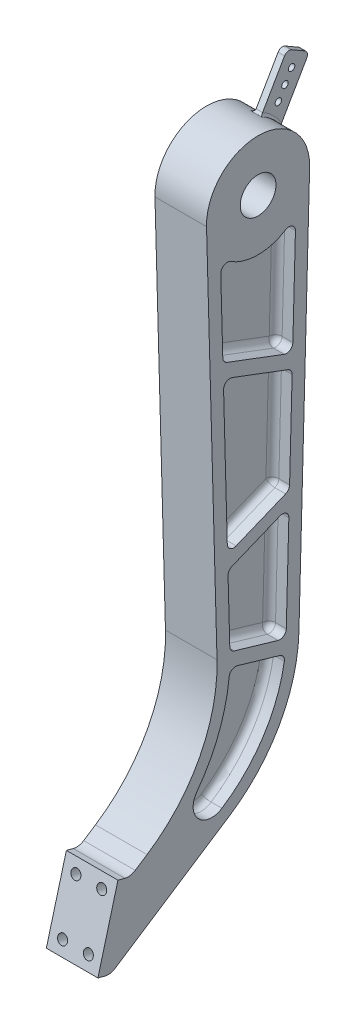
from build123d import *

# Parameters (mm, degrees)
SKETCH1_R            = 8.8003507
BOSS_EXTRUDE1_DEPTH  = 12.7
CUT_EXTRUDE1_DEPTH   = 8.466666667
FILLET1_R            = 3.175
FILLET1_OF_MIRROR2_R = 3.175
SKETCH3_R            = 2.38125
CUT_EXTRUDE2_DEPTH   = 7.9375
BOSS_EXTRUDE2_DEPTH  = 1.5875
CUT_EXTRUDE3_REACH   = 308.22
SKETCH5_R            = 1.5875
FILLET2_R            = 1.27


with BuildPart() as part:
    # Sketch1 → Boss-Extrude1 (new, symmetric)
    with BuildSketch(Plane(origin=(0, 0, 0), x_dir=(0, 0, -1), z_dir=(1, 0, 0))):
        with BuildLine():
            Line((-25.39034411, -0.700304185), (-20.223925011, -188.014847764))
            ThreePointArc((-20.223925011, -188.014847764), (-28.875615942, -225.436838118), (-54.68211929, -253.884711554))
            Line((-54.68211929, -253.884711554), (-60.516881835, -257.701373117))
            ThreePointArc((-60.516881835, -257.701373117), (-62.989212347, -258.657461897), (-65.636452609, -258.520922845))
            Line((-65.636452609, -258.520922845), (-69.027039329, -257.612417871))
            Line((-69.027039329, -257.612417871), (-78.888044947, -294.414191853))
            Line((-78.888044947, -294.414191853), (-75.497458227, -295.322696826))
            ThreePointArc((-75.497458227, -295.322696826), (-72.850217966, -295.459235879), (-70.377887453, -294.503147099))
            Line((-70.377887453, -294.503147099), (-14.336567795, -257.845142759))
            ThreePointArc((-14.336567795, -257.845142759), (10.482969023, -231.222969231), (20.123027121, -196.125692826))
            Line((20.123027121, -196.125692826), (25.4, 0))
            ThreePointArc((25.4, 0), (-0.350185375, 25.397585913), (-25.39034411, -0.700304185))
        make_face()
        Circle(SKETCH1_R, mode=Mode.SUBTRACT)
    extrude(amount=BOSS_EXTRUDE1_DEPTH, both=True)

    # Sketch2 → Cut-Extrude1 (cut)
    with BuildSketch(Plane(origin=(12.7, 0, 0), x_dir=(0, 0, -1), z_dir=(1, 0, 0))):
        with BuildLine():
            Line((-11.660302985, -188.490127485), (9.818309103, -194.793607776))
            ThreePointArc((9.818309103, -194.793607776), (12.580917397, -194.314044839), (13.886242269, -191.832490452))
            Line((13.886242269, -191.832490452), (15.141700078, -145.171736569))
            ThreePointArc((15.141700078, -145.171736569), (13.770751444, -142.472881917), (10.760959128, -142.149668662))
            Line((10.760959128, -142.149668662), (-12.818942026, -151.840344616))
            ThreePointArc((-12.818942026, -151.840344616), (-14.273641559, -153.045956724), (-14.785845463, -154.864554658))
            Line((-14.785845463, -154.864554658), (-13.940014207, -185.531152296))
            ThreePointArc((-13.940014207, -185.531152296), (-13.281332503, -187.381355252), (-11.660302985, -188.490127485))
        make_face()
        with BuildLine():
            Line((15.515269566, -131.287531301), (16.765792896, -84.810173886))
            ThreePointArc((16.765792896, -84.810173886), (16.228003809, -82.955088584), (14.71468148, -81.754916051))
            Line((14.71468148, -81.754916051), (-12.693209932, -71.393513614))
            ThreePointArc((-12.693209932, -71.393513614), (-15.656229887, -71.776100059), (-16.989779352, -74.449581958))
            Line((-16.989779352, -74.449581958), (-15.174226134, -141.292142862))
            ThreePointArc((-15.174226134, -141.292142862), (-13.732014902, -143.867162368), (-10.793507095, -144.142608485))
            Line((-10.793507095, -144.142608485), (13.548307769, -134.138807433))
            ThreePointArc((13.548307769, -134.138807433), (14.954876957, -133.005038153), (15.515269566, -131.287531301))
        make_face()
        with BuildLine():
            Line((-15.331296871, -63.607584159), (12.830833159, -74.254122353))
            ThreePointArc((12.830833159, -74.254122353), (15.723262531, -73.920322691), (17.12742449, -71.369656293))
            Line((17.12742449, -71.369656293), (18.394713184, -24.269191925))
            ThreePointArc((18.394713184, -24.269191925), (16.792875178, -21.425282131), (13.529654942, -21.496707589))
            ThreePointArc((13.529654942, -21.496707589), (0.003660623, -25.399999736), (-13.523458211, -21.500606457))
            ThreePointArc((-13.523458211, -21.500606457), (-16.787232142, -21.430425741), (-18.387683501, -24.275720287))
            Line((-18.387683501, -24.275720287), (-17.382349928, -60.725260234))
            ThreePointArc((-17.382349928, -60.725260234), (-16.7954463, -62.478544936), (-15.331296871, -63.607584159))
        make_face()
        with BuildLine():
            Line((-10.195205463, -195.537911468), (10.666732473, -201.660412031))
            ThreePointArc((10.666732473, -201.660412031), (12.458283079, -203.013407124), (12.907034325, -205.213150658))
            ThreePointArc((12.907034325, -205.213150658), (2.53678877, -232.111442282), (-17.812637633, -252.531063489))
            ThreePointArc((-17.812637633, -252.531063489), (-29.49364525, -251.143961365), (-30.171678071, -239.400441332))
            ThreePointArc((-30.171678071, -239.400441332), (-19.412569014, -219.918686135), (-14.248756518, -198.270770444))
            ThreePointArc((-14.248756518, -198.270770444), (-12.864146304, -195.95184033), (-10.195205463, -195.537911468))
        make_face()
    cut_extrude1 = extrude(amount=-CUT_EXTRUDE1_DEPTH, mode=Mode.SUBTRACT)

    # Fillet1
    fillet1_edges = [part.edges().sort_by_distance(p)[0] for p in [
        (4.233333333, -219.918686135, 19.412569014),
        (4.233333333, -195.95184033, 12.864146304),
        (4.233333333, -198.59916175, -0.235763505),
        (4.233333333, -203.013407124, -12.458283079),
        (4.233333333, -232.111442282, -2.53678877),
        (4.233333333, -251.143961365, 29.49364525),
        (4.233333333, -194.314044839, -12.580917397),
        (4.233333333, -191.64186763, 0.920996941),
        (4.233333333, -187.381355252, 13.281332503),
        (4.233333333, -170.197853477, 14.362929835),
        (4.233333333, -153.045956724, 14.273641559),
        (4.233333333, -146.995006639, 1.028991449),
        (4.233333333, -142.472881917, -13.770751444),
        (4.233333333, -168.50211351, -14.513971173),
        (4.233333333, -133.005038153, -14.954876957),
        (4.233333333, -139.140707959, -1.377400337),
        (4.233333333, -143.867162368, 13.732014902),
        (4.233333333, -107.87086241, 16.082002743),
        (4.233333333, -71.776100059, 15.656229887),
        (4.233333333, -76.574214832, -1.010735774),
        (4.233333333, -82.955088584, -16.228003809),
        (4.233333333, -108.048852594, -16.140531231),
        (4.233333333, -21.425282131, -16.792875178),
        (4.233333333, -47.819424109, -17.761068837),
        (4.233333333, -73.920322691, -15.723262531),
        (4.233333333, -68.930853256, 1.250231856),
        (4.233333333, -62.478544936, 16.7954463),
        (4.233333333, -42.500490261, 17.885016715),
        (4.233333333, -21.430425741, 16.787232142),
        (4.233333333, -25.399999736, -0.003660623),
    ]]
    fillet(fillet1_edges, radius=FILLET1_R)

    # Mirror2: Cut-Extrude1 across plane
    add(cut_extrude1.mirror(Plane(origin=(0, 0, 0), x_dir=(0, 0, 1), z_dir=(1, 0, 0))), mode=Mode.SUBTRACT)

    # Fillet1 of Mirror2
    fillet1_of_mirror2_edges = [part.edges().sort_by_distance(p)[0] for p in [
        (-4.233333333, -219.918686135, 19.412569014),
        (-4.233333333, -195.95184033, 12.864146304),
        (-4.233333333, -198.59916175, -0.235763505),
        (-4.233333333, -203.013407124, -12.458283079),
        (-4.233333333, -232.111442282, -2.53678877),
        (-4.233333333, -251.143961365, 29.49364525),
        (-4.233333333, -194.314044839, -12.580917397),
        (-4.233333333, -191.64186763, 0.920996941),
        (-4.233333333, -187.381355252, 13.281332503),
        (-4.233333333, -170.197853477, 14.362929835),
        (-4.233333333, -153.045956724, 14.273641559),
        (-4.233333333, -146.995006639, 1.028991449),
        (-4.233333333, -142.472881917, -13.770751444),
        (-4.233333333, -168.50211351, -14.513971173),
        (-4.233333333, -133.005038153, -14.954876957),
        (-4.233333333, -139.140707959, -1.377400337),
        (-4.233333333, -143.867162368, 13.732014902),
        (-4.233333333, -107.87086241, 16.082002743),
        (-4.233333333, -71.776100059, 15.656229887),
        (-4.233333333, -76.574214832, -1.010735774),
        (-4.233333333, -82.955088584, -16.228003809),
        (-4.233333333, -108.048852594, -16.140531231),
        (-4.233333333, -21.425282131, -16.792875178),
        (-4.233333333, -47.819424109, -17.761068837),
        (-4.233333333, -73.920322691, -15.723262531),
        (-4.233333333, -68.930853256, 1.250231856),
        (-4.233333333, -62.478544936, 16.7954463),
        (-4.233333333, -42.500490261, 17.885016715),
        (-4.233333333, -21.430425741, 16.787232142),
        (-4.233333333, -25.399999736, -0.003660623),
    ]]
    fillet(fillet1_of_mirror2_edges, radius=FILLET1_OF_MIRROR2_R)

    # Sketch3 → Cut-Extrude2 (cut)
    with BuildSketch(Plane(origin=(0, 0, 0), x_dir=(1, 0, 0), z_dir=(0, 0.25881904510252113, 0.9659258262890683))):
        with Locations(Location((6.35, -273.05, 0), (0, 0, 270))):
            Circle(SKETCH3_R)
        with Locations(Location((6.35, -298.45, 0), (0, 0, 270))):
            Circle(SKETCH3_R)
        with Locations(Location((-6.35, -298.45, 0), (0, 0, 270))):
            Circle(SKETCH3_R)
        with Locations(Location((-6.35, -273.05, 0), (0, 0, 270))):
            Circle(SKETCH3_R)
    extrude(amount=-CUT_EXTRUDE2_DEPTH, mode=Mode.SUBTRACT)

    # Sketch4 → Boss-Extrude2 (add, symmetric)
    with BuildSketch(Plane(origin=(0, 0, 0), x_dir=(0, 0, -1), z_dir=(1, 0, 0))):
        with BuildLine():
            Line((12.7, 21.997045256), (24.13, 41.794385987))
            ThreePointArc((24.13, 41.794385987), (25.672304151, 42.977837585), (27.599704526, 42.724090512))
            Line((27.599704526, 42.724090512), (34.198818102, 38.914090512))
            ThreePointArc((34.198818102, 38.914090512), (35.382269701, 37.371786361), (35.128522628, 35.444385987))
            Line((35.128522628, 35.444385987), (21.997045256, 12.7))
            ThreePointArc((21.997045256, 12.7), (17.960512242, 17.960512242), (12.7, 21.997045256))
        make_face()
    extrude(amount=BOSS_EXTRUDE2_DEPTH, both=True)

    # Sketch5 → Cut-Extrude3 (cut, up to next)
    with BuildSketch(Plane(origin=(1.5875, 0, 0), x_dir=(0, 0, -1), z_dir=(1, 0, 0)), mode=Mode.PRIVATE) as cut_extrude3_sk1:
        with Locations((24.347622376, 29.471318999)):
            Circle(SKETCH5_R)
    cut_extrude3_tool1 = extrude(cut_extrude3_sk1.sketch, amount=-CUT_EXTRUDE3_REACH, mode=Mode.PRIVATE) & part.part
    # Sketch5 → Cut-Extrude3 (cut, up to next)
    with BuildSketch(Plane(origin=(1.5875, 0, 0), x_dir=(0, 0, -1), z_dir=(1, 0, 0)), mode=Mode.PRIVATE) as cut_extrude3_sk2:
        with Locations((27.623441834, 35.145204737)):
            Circle(SKETCH5_R)
    cut_extrude3_tool2 = extrude(cut_extrude3_sk2.sketch, amount=-CUT_EXTRUDE3_REACH, mode=Mode.PRIVATE) & part.part
    # Sketch5 → Cut-Extrude3 (cut, up to next)
    with BuildSketch(Plane(origin=(1.5875, 0, 0), x_dir=(0, 0, -1), z_dir=(1, 0, 0)), mode=Mode.PRIVATE) as cut_extrude3_sk3:
        with Locations((21.071802918, 23.797433261)):
            Circle(SKETCH5_R)
    cut_extrude3_tool3 = extrude(cut_extrude3_sk3.sketch, amount=-CUT_EXTRUDE3_REACH, mode=Mode.PRIVATE) & part.part
    add(cut_extrude3_tool1.solids().sort_by_distance((1.5875, 29.471319, -24.347622))[0], mode=Mode.SUBTRACT)
    add(cut_extrude3_tool2.solids().sort_by_distance((1.5875, 35.145205, -27.623442))[0], mode=Mode.SUBTRACT)
    add(cut_extrude3_tool3.solids().sort_by_distance((1.5875, 23.797433, -21.071803))[0], mode=Mode.SUBTRACT)

    # Fillet2
    fillet2_edges = [part.edges().sort_by_distance(p)[0] for p in [
        (-1.5875, 17.960512242, -17.960512242),
        (0, 12.7, -21.997045256),
        (0, 21.997045256, -12.7),
        (1.5875, 17.960512242, -17.960512242),
    ]]
    fillet(fillet2_edges, radius=FILLET2_R)


solid = part.part
